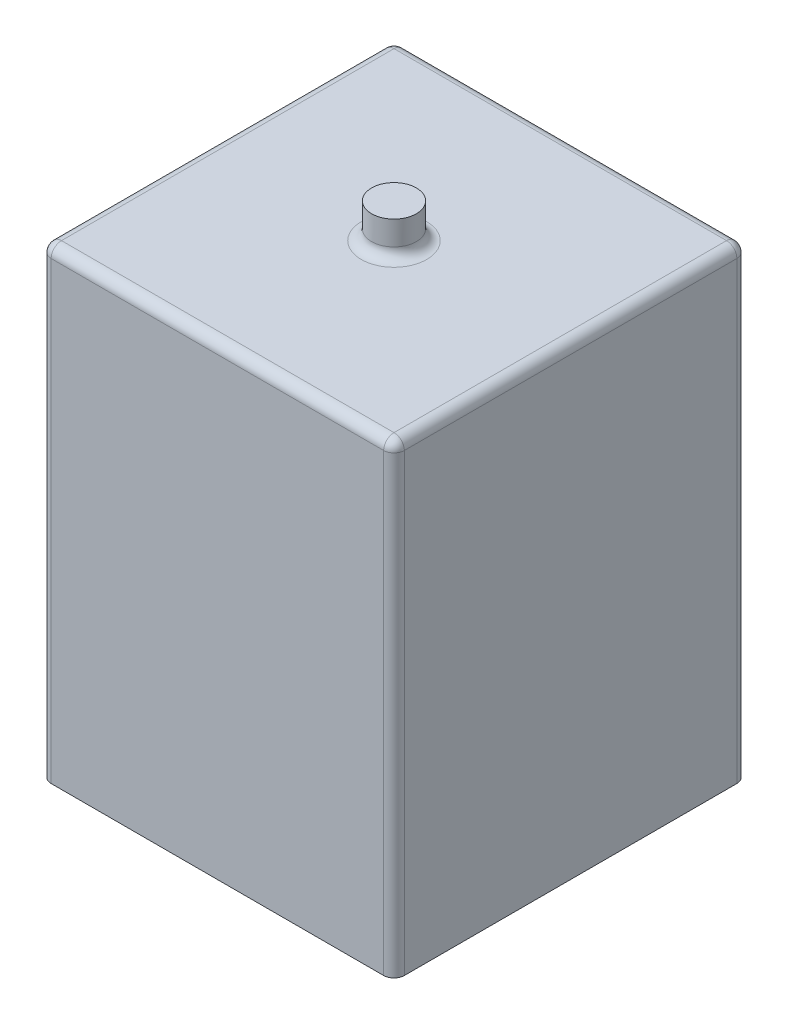
from build123d import *

# Parameters (mm, degrees)
SKETCH1_W           = 10.253048328
SKETCH1_H           = 10.253048328
BOSS_EXTRUDE1_DEPTH = 13.5
SKETCH2_R           = 0.65
BOSS_EXTRUDE2_DEPTH = 1
FILLET3_R           = 0.3


with BuildPart() as part:
    # Sketch1 → Boss-Extrude1 (new body)
    with BuildSketch(Plane(origin=(0, 0, 0), x_dir=(1, 0, 0), z_dir=(0, 1, 0))):
        Rectangle(SKETCH1_W, SKETCH1_H)
    extrude(amount=BOSS_EXTRUDE1_DEPTH)

    # Sketch2 → Boss-Extrude2 (add)
    with BuildSketch(Plane(origin=(0, 13.5, 0), x_dir=(1, 0, 0), z_dir=(0, 1, 0))):
        with Locations(Location((0, 0, 0), (0, 0, 90))):  # turned: the seam where the file's is
            Circle(SKETCH2_R)
    extrude(amount=BOSS_EXTRUDE2_DEPTH)

    # Fillet3
    fillet3_edges = [part.edges().sort_by_distance(p)[0] for p in [
        (-5.126524164, 13.5, 0),
        (0, 13.5, 0.65),
        (0, 13.5, 5.126524164),
        (5.126524164, 13.5, 0),
        (5.126524164, 6.75, 5.126524164),
        (-5.126524164, 6.75, 5.126524164),
        (-5.126524164, 6.75, -5.126524164),
        (5.126524164, 6.75, -5.126524164),
        (0, 13.5, -5.126524164),
    ]]
    fillet(fillet3_edges, radius=FILLET3_R)


solid = part.part
